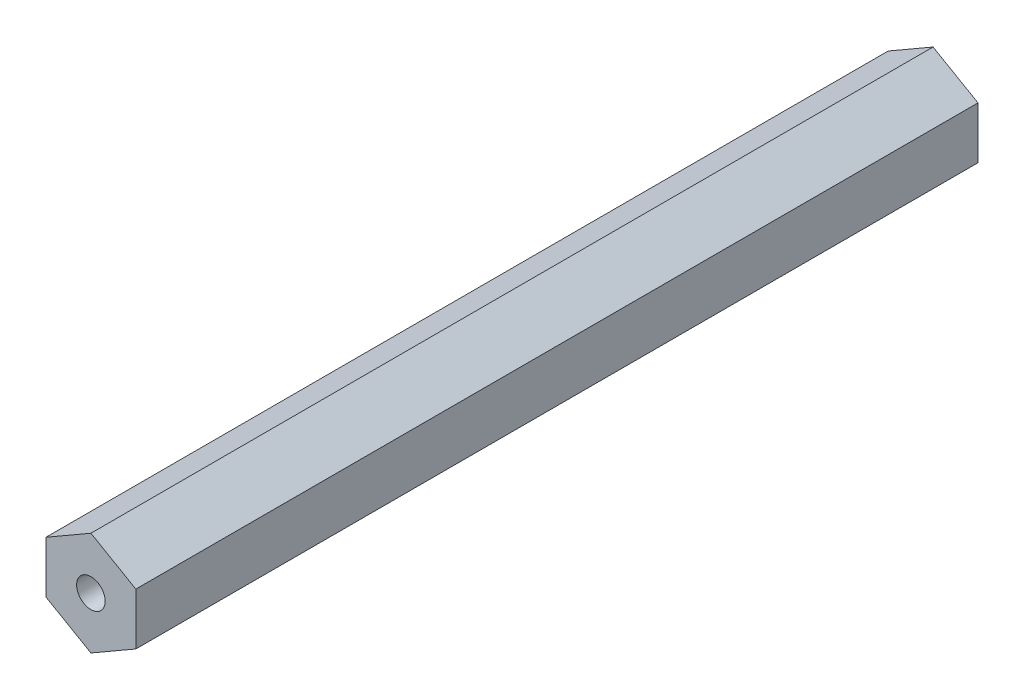
from build123d import *

# Parameters (mm, degrees)
BOSS_EXTRUDE1_DEPTH         = 119.0625
F_1_4_20_TAPPED_HOLE2_D     = 5.1054
F_1_4_20_TAPPED_HOLE2_DEPTH = 16.51
F_1_4_20_TAPPED_HOLE2_TIP   = 1.533816902
F_10_32_TAPPED_HOLE1_D      = 4.0386
F_10_32_TAPPED_HOLE1_DEPTH  = 13.6144
F_10_32_TAPPED_HOLE1_TIP    = 1.213317848


with BuildPart() as part:
    # Sketch1 → Boss-Extrude1 (new body)
    with BuildSketch(Plane.XY):
        Polygon((0, 7.332348419), (-6.35, 3.666174209), (-6.35, -3.666174209), (0, -7.332348419), (6.35, -3.666174209), (6.35, 3.666174209), align=None)
    extrude(amount=BOSS_EXTRUDE1_DEPTH)

    # 1/4-20 Tapped Hole2
    with Locations(Plane(origin=(0, 0, 0), x_dir=(-1, 0, 0), z_dir=(0, 0, -1))):
        with Locations((0, 0)):
            Hole(F_1_4_20_TAPPED_HOLE2_D / 2, depth=F_1_4_20_TAPPED_HOLE2_DEPTH)
            with Locations((0, 0, -(F_1_4_20_TAPPED_HOLE2_DEPTH + F_1_4_20_TAPPED_HOLE2_TIP / 2))):  # 118° drill point
                Cone(0, F_1_4_20_TAPPED_HOLE2_D / 2, F_1_4_20_TAPPED_HOLE2_TIP, mode=Mode.SUBTRACT)

    # #10-32 Tapped Hole1
    with Locations(Plane.XY.offset(119.0625)):
        with Locations((0, 0)):
            Hole(F_10_32_TAPPED_HOLE1_D / 2, depth=F_10_32_TAPPED_HOLE1_DEPTH)
            with Locations((0, 0, -(F_10_32_TAPPED_HOLE1_DEPTH + F_10_32_TAPPED_HOLE1_TIP / 2))):  # 118° drill point
                Cone(0, F_10_32_TAPPED_HOLE1_D / 2, F_10_32_TAPPED_HOLE1_TIP, mode=Mode.SUBTRACT)


solid = part.part
